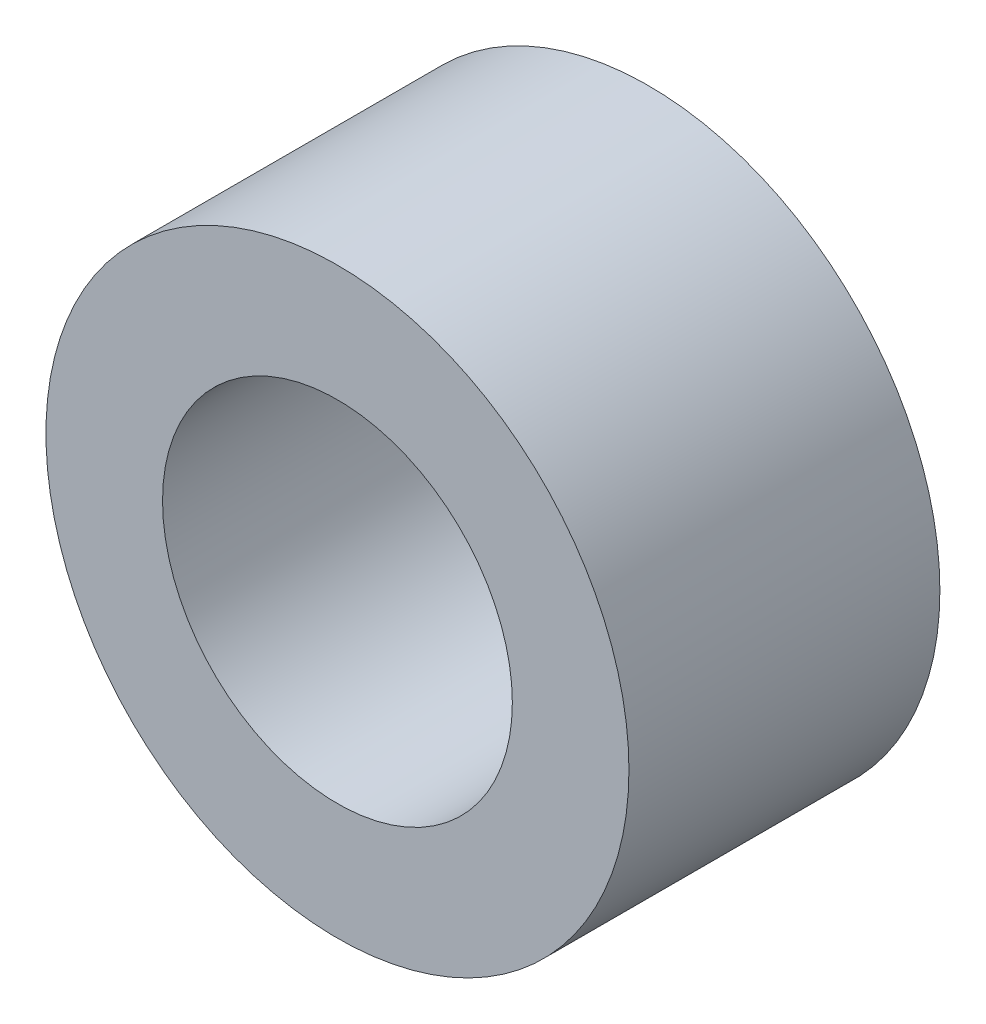
from build123d import *

# Parameters (mm, degrees)
SKETCH1_R           = 3.75
SKETCH1_R_2         = 2.25
BOSS_EXTRUDE1_DEPTH = 4


with BuildPart() as part:
    # Sketch1 → Boss-Extrude1 (new body)
    with BuildSketch(Plane.XY):
        Circle(SKETCH1_R)
        Circle(SKETCH1_R_2, mode=Mode.SUBTRACT)
    extrude(amount=BOSS_EXTRUDE1_DEPTH)


solid = part.part
